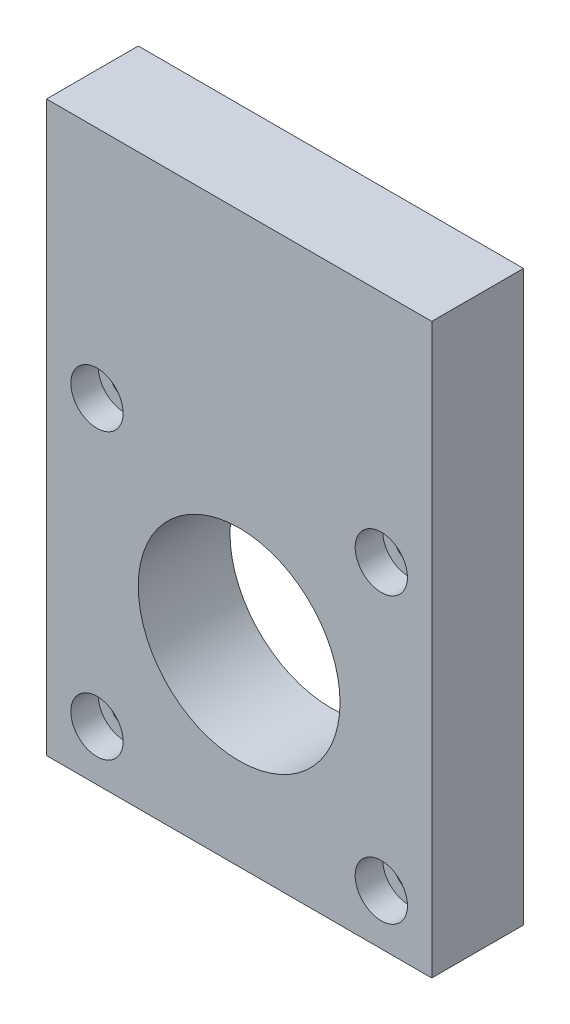
from build123d import *

# Parameters (mm, degrees)
SKETCH1_W           = 42
SKETCH1_H           = 62
BOSS_EXTRUDE1_DEPTH = 10
SKETCH2_R           = 1.5
SKETCH2_R_2         = 11
CUT_EXTRUDE1_DEPTH  = 11
SKETCH3_R           = 2.85
CUT_EXTRUDE2_DEPTH  = 3


with BuildPart() as part:
    # Sketch1 → Boss-Extrude1 (new body)
    with BuildSketch(Plane.XY):
        Rectangle(SKETCH1_W, SKETCH1_H)
    extrude(amount=BOSS_EXTRUDE1_DEPTH)

    # Sketch2 → Cut-Extrude1 (cut, through all)
    with BuildSketch(Plane(origin=(0, 0, 0), x_dir=(-1, 0, 0), z_dir=(0, 0, -1))):
        with Locations((15.5, 5.5)):
            Circle(SKETCH2_R)
        with Locations((15.5, -25.5)):
            Circle(SKETCH2_R)
        with Locations((-15.5, -25.5)):
            Circle(SKETCH2_R)
        with Locations((-15.5, 5.5)):
            Circle(SKETCH2_R)
        with Locations((0, -10)):
            Circle(SKETCH2_R_2)
    extrude(amount=-CUT_EXTRUDE1_DEPTH, mode=Mode.SUBTRACT)

    # Sketch3 → Cut-Extrude2 (cut)
    with BuildSketch(Plane.XY.offset(10)):
        with Locations((-15.5, 5.5)):
            Circle(SKETCH3_R)
        with Locations((15.5, 5.5)):
            Circle(SKETCH3_R)
        with Locations((15.5, -25.5)):
            Circle(SKETCH3_R)
        with Locations((-15.5, -25.5)):
            Circle(SKETCH3_R)
    extrude(amount=-CUT_EXTRUDE2_DEPTH, mode=Mode.SUBTRACT)


solid = part.part
